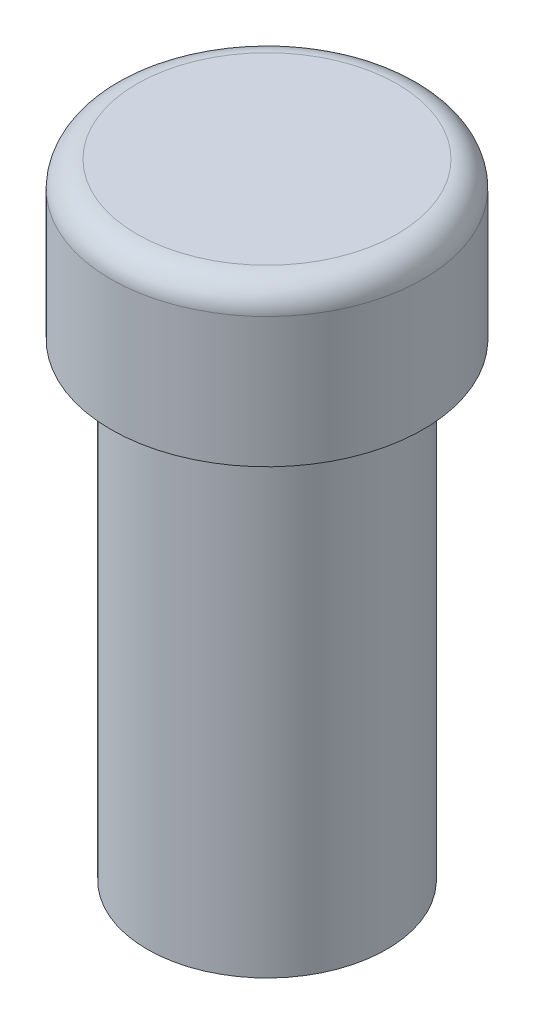
from build123d import *

# Parameters (mm, degrees)
SKETCH1_R           = 3
BOSS_EXTRUDE1_DEPTH = 3
FILLET1_R           = 0.5
SKETCH2_R           = 2.3
BOSS_EXTRUDE2_DEPTH = 9


with BuildPart() as part:
    # Sketch1 → Boss-Extrude1 (new body)
    with BuildSketch(Plane(origin=(0, 0, 0), x_dir=(1, 0, 0), z_dir=(0, 1, 0))):
        Circle(SKETCH1_R)
    extrude(amount=BOSS_EXTRUDE1_DEPTH)

    # Fillet1
    fillet1_edges = [part.edges().sort_by_distance(p)[0] for p in [
        (-3, 3, 0),
    ]]
    fillet(fillet1_edges, radius=FILLET1_R)

    # Sketch2 → Boss-Extrude2 (add)
    with BuildSketch(Plane.XZ):
        Circle(SKETCH2_R)
    extrude(amount=BOSS_EXTRUDE2_DEPTH)


solid = part.part
